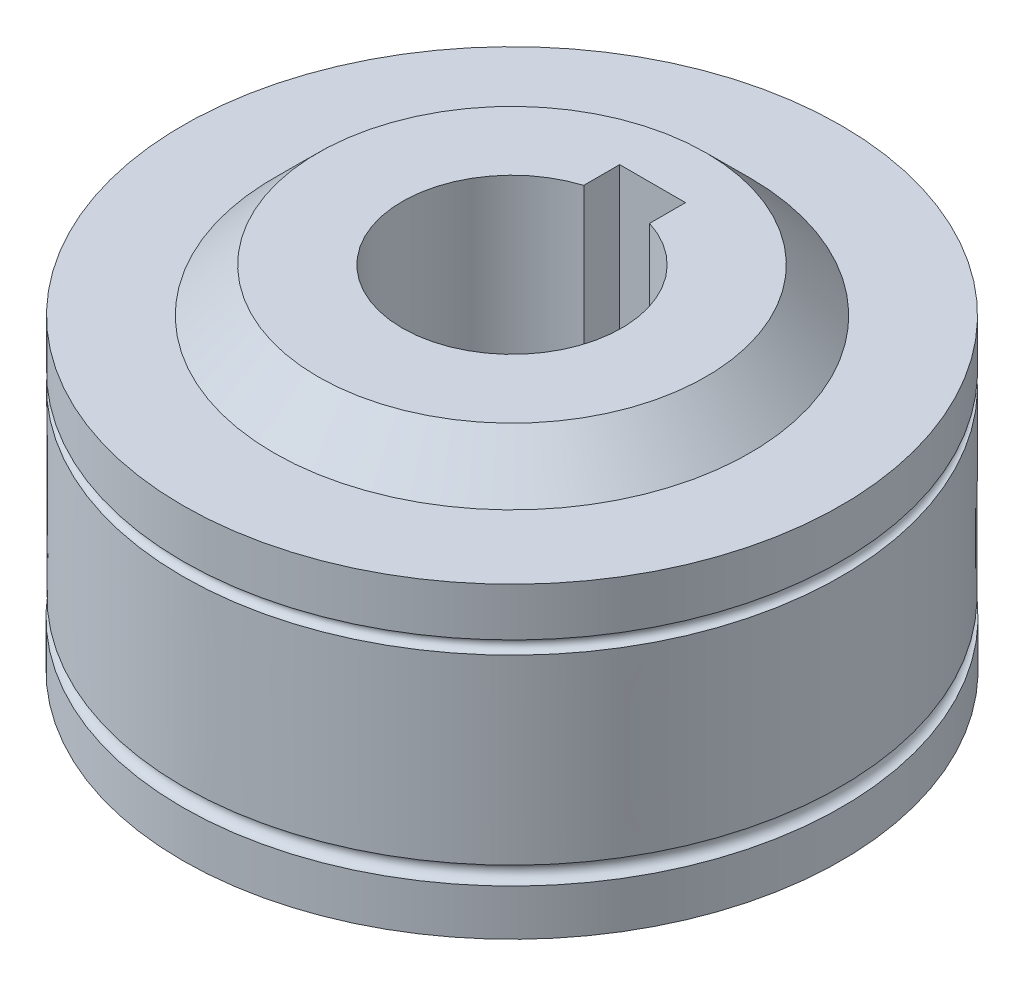
from build123d import *

# Parameters (mm, degrees)
SKETCH_2_W          = 3
SKETCH_2_H          = 2.405661247
CUT_EXTRUDE_1_DEPTH = 19


with BuildPart() as part:
    # Эскиз1 → Повернуть1 (revolve)
    with BuildSketch(Plane(origin=(0, 0, 0), x_dir=(0, 0, -1), z_dir=(1, 0, 0))):
        with BuildLine():
            Line((15, 7), (15, 4.8))
            ThreePointArc((15, 4.8), (14.7, 4.5), (15, 4.2))
            Line((15, 4.2), (14.982695469, -4.100374484))
            ThreePointArc((14.982695469, -4.100374484), (14.600374484, -4.517304531), (15.017304531, -4.899625516))
            Line((15.017304531, -4.899625516), (15.017304531, -7))
            Line((15.017304531, -7), (10.850882415, -7))
            Line((10.850882415, -7), (8.840023423, -9))
            Line((8.840023423, -9), (5, -9))
            Line((5, -9), (5, 9))
            Line((5, 9), (8.840023423, 9))
            Line((8.840023423, 9), (10.850882415, 7))
            Line((10.850882415, 7), (15, 7))
        make_face()
    revolve(axis=Axis((0, 26.633173064, 0), (0, -1, 0)))

    # Эскиз2 → Вырез-Вытянуть1 (cut, through all)
    with BuildSketch(Plane(origin=(0, 9, 0), x_dir=(1, 0, 0), z_dir=(0, 1, 0))):
        with Locations((0, 5.202830624)):
            Rectangle(SKETCH_2_W, SKETCH_2_H)
    extrude(amount=-CUT_EXTRUDE_1_DEPTH, mode=Mode.SUBTRACT)


solid = part.part
